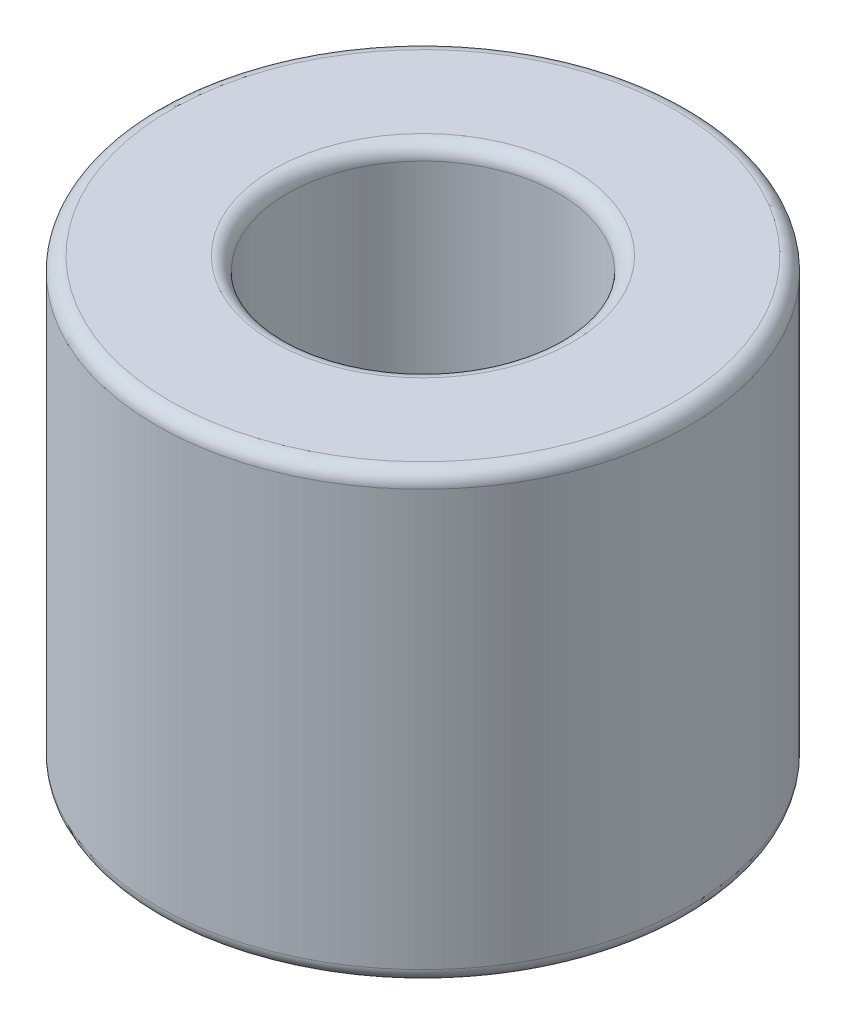
from build123d import *

# Parameters (mm, degrees)
ESQUISSE2_R        = 9.525
ESQUISSE2_R_2      = 4.8514
BOSS_EXTRU_1_DEPTH = 7.9375
CONG_2_R           = 0.5


with BuildPart() as part:
    # Esquisse2 → Boss.-Extru.1 (new body, symmetric)
    with BuildSketch(Plane(origin=(0, 0, 0), x_dir=(1, 0, 0), z_dir=(0, 1, 0))):
        Circle(ESQUISSE2_R)
        Circle(ESQUISSE2_R_2, mode=Mode.SUBTRACT)
    extrude(amount=BOSS_EXTRU_1_DEPTH, both=True)

    # Congé2
    cong_2_edges = [part.edges().sort_by_distance(p)[0] for p in [
        (-9.525, -7.9375, 0),
        (-9.525, 7.9375, 0),
        (-4.8514, -7.9375, 0),
        (-4.8514, 7.9375, 0),
    ]]
    fillet(cong_2_edges, radius=CONG_2_R)


solid = part.part
